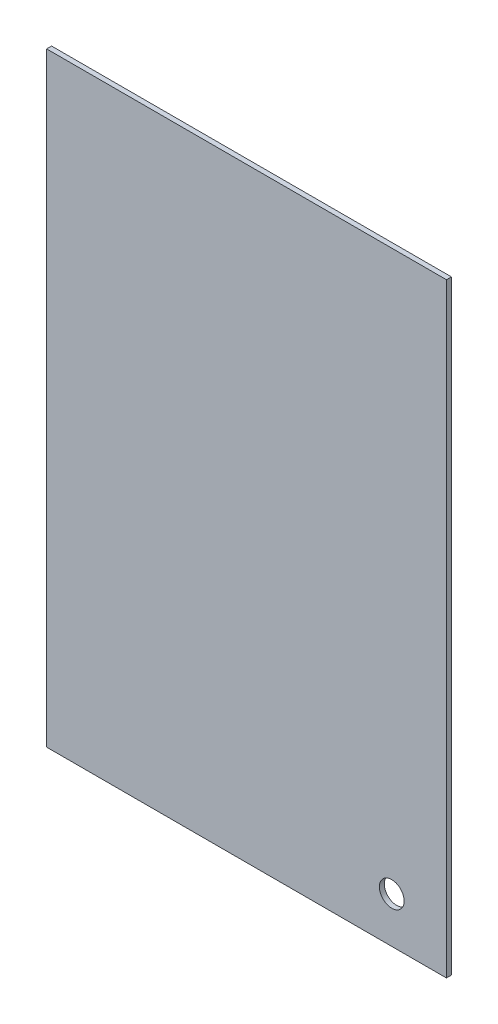
from build123d import *

# Parameters (mm, degrees)
SKETCH1_W           = 242
SKETCH1_H           = 366
BOSS_EXTRUDE1_DEPTH = 3
CUT_EXTRUDE1_REACH  = 5
SKETCH2_R           = 7.5


with BuildPart() as part:
    # Sketch1 → Boss-Extrude1 (new body)
    with BuildSketch(Plane.XY):
        Rectangle(SKETCH1_W, SKETCH1_H)
    extrude(amount=BOSS_EXTRUDE1_DEPTH)

    # Sketch2 → Cut-Extrude1 (cut, up to next)
    with BuildSketch(Plane.XY.offset(3), mode=Mode.PRIVATE) as cut_extrude1_sk1:
        with Locations((87.9, -155.5)):
            Circle(SKETCH2_R)
    cut_extrude1_tool1 = extrude(cut_extrude1_sk1.sketch, amount=-CUT_EXTRUDE1_REACH, mode=Mode.PRIVATE) & part.part
    add(cut_extrude1_tool1.solids().sort_by_distance((87.9, -155.5, 3))[0], mode=Mode.SUBTRACT)


solid = part.part
